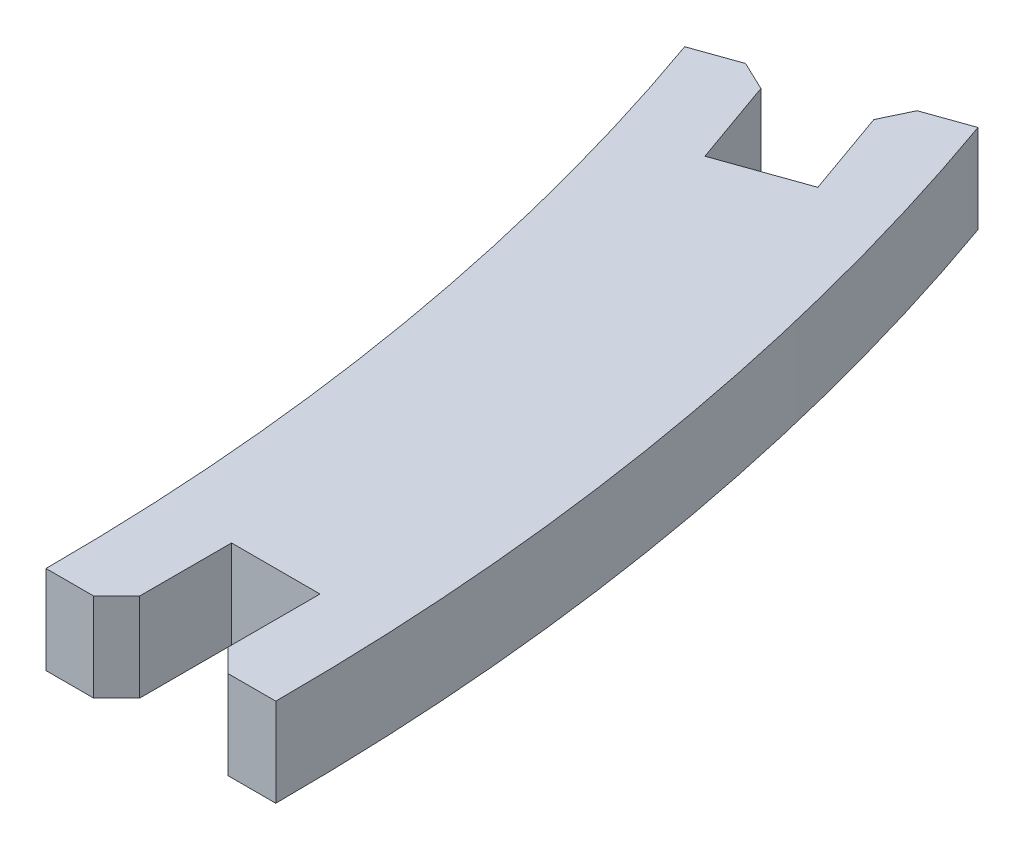
from build123d import *

# Parameters (mm, degrees)
BOSS_EXTRUDE1_DEPTH = 3.85
CHAMFER1_SIZE       = 1


with BuildPart() as part:
    # Sketch1 → Boss-Extrude1 (new body)
    with BuildSketch(Plane(origin=(0, 0, 0), x_dir=(1, 0, 0), z_dir=(0, 1, 0))):
        with BuildLine():
            Line((-17.644097819, 33.396892859), (-14.745475234, 34.423348951))
            Line((-14.745475234, 34.423348951), (-13.076440938, 29.710141496))
            Line((-13.076440938, 29.710141496), (-9.447271197, 30.995297904))
            Line((-9.447271197, 30.995297904), (-11.116305493, 35.708505359))
            Line((-11.116305493, 35.708505359), (-8.217682908, 36.734961451))
            ThreePointArc((-8.217682908, 36.734961451), (-3.473682306, 18.55498598), (-1.876973594, -0.165793148))
            Line((-1.876973594, -0.165793148), (-4.951973594, -0.165793148))
            Line((-4.951973594, -0.165793148), (-4.951973594, 4.834206852))
            Line((-4.951973594, 4.834206852), (-8.801973594, 4.834206852))
            Line((-8.801973594, 4.834206852), (-8.801973594, -0.165793148))
            Line((-8.801973594, -0.165793148), (-11.876973594, -0.165793148))
            ThreePointArc((-11.876973594, -0.165793148), (-13.329242897, 16.861490941), (-17.644097819, 33.396892859))
        make_face()
    extrude(amount=BOSS_EXTRUDE1_DEPTH)

    # Chamfer1
    chamfer1_edges = [part.edges().sort_by_distance(p)[0] for p in [
        (-14.745475234, 1.925, -34.423348951),
        (-11.116305493, 1.925, -35.708505359),
        (-4.951973594, 1.925, 0.165793148),
        (-8.801973594, 1.925, 0.165793148),
    ]]
    chamfer(chamfer1_edges, length=CHAMFER1_SIZE)


solid = part.part
